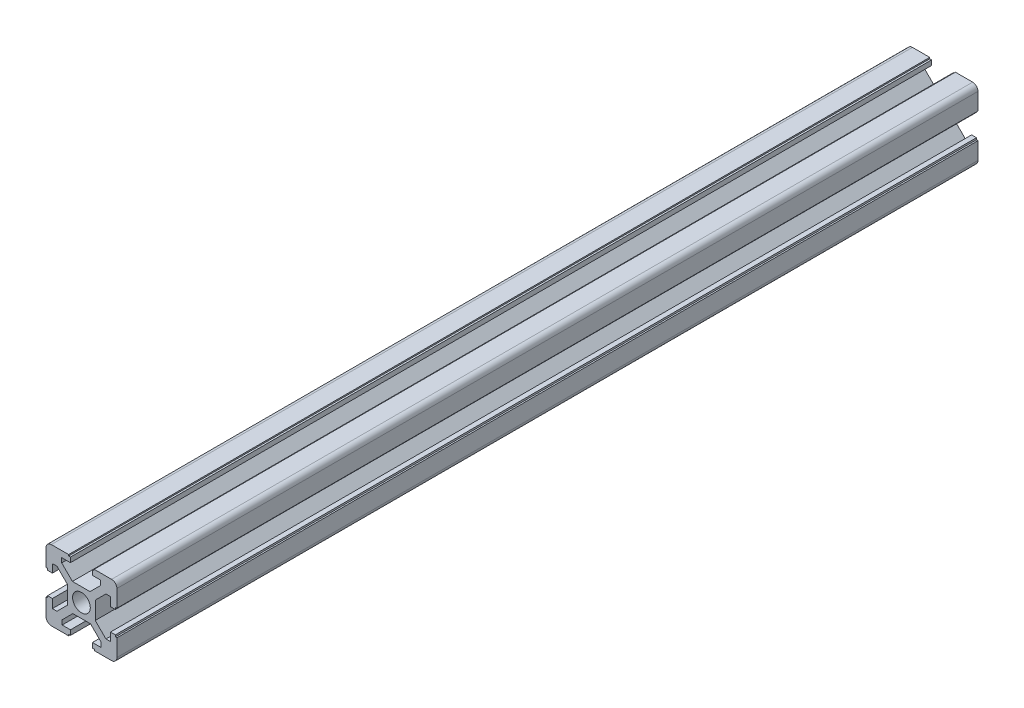
from build123d import *

# Parameters (mm, degrees)
SKETCH1_R           = 2.5
BOSS_EXTRUDE1_DEPTH = 243


with BuildPart() as part:
    # Sketch1 → Boss-Extrude1 (new body)
    with BuildSketch(Plane.XY):
        with BuildLine():
            Line((14.316619525, 10.387216168), (13.029112559, 10.387216168))
            Line((13.029112559, 10.387216168), (13.029112559, 12.855371932))
            Line((13.029112559, 12.855371932), (11.656738465, 12.855371932))
            Line((11.656738465, 12.855371932), (11.656738465, 12.336659272))
            Line((11.656738465, 12.336659272), (11.229112559, 12.336659272))
            Line((11.229112559, 12.336659272), (11.229112559, 7.521203168))
            ThreePointArc((11.229112559, 7.521203168), (11.668452387, 6.460542996), (12.729112559, 6.021203168))
            Line((12.729112559, 6.021203168), (17.624436699, 6.021203168))
            Line((17.624436699, 6.021203168), (17.624436699, 6.382997838))
            Line((17.624436699, 6.382997838), (18.129112559, 6.382997838))
            Line((18.129112559, 6.382997838), (18.129112559, 7.755371932))
            Line((18.129112559, 7.755371932), (15.794230869, 7.755371932))
            Line((15.794230869, 7.755371932), (15.794230869, 9.042878898))
            Line((15.794230869, 9.042878898), (18.806723903, 12.055371932))
            Line((18.806723903, 12.055371932), (23.784775289, 12.055371932))
            Line((23.784775289, 12.055371932), (26.797268323, 9.042878898))
            Line((26.797268323, 9.042878898), (26.797268323, 7.755371932))
            Line((26.797268323, 7.755371932), (24.329112559, 7.755371932))
            Line((24.329112559, 7.755371932), (24.329112559, 6.382997838))
            Line((24.329112559, 6.382997838), (24.847825219, 6.382997838))
            Line((24.847825219, 6.382997838), (24.847825219, 6.021203168))
            Line((24.847825219, 6.021203168), (29.729112559, 6.021203168))
            ThreePointArc((29.729112559, 6.021203168), (30.789772731, 6.460542996), (31.229112559, 7.521203168))
            Line((31.229112559, 7.521203168), (31.229112559, 12.350696072))
            Line((31.229112559, 12.350696072), (30.801486653, 12.350696072))
            Line((30.801486653, 12.350696072), (30.801486653, 12.855371932))
            Line((30.801486653, 12.855371932), (29.429112559, 12.855371932))
            Line((29.429112559, 12.855371932), (29.429112559, 10.520490242))
            Line((29.429112559, 10.520490242), (28.141605593, 10.520490242))
            Line((28.141605593, 10.520490242), (25.129112559, 13.532983276))
            Line((25.129112559, 13.532983276), (25.129112559, 18.511034662))
            Line((25.129112559, 18.511034662), (28.141605593, 21.523527696))
            Line((28.141605593, 21.523527696), (29.429112559, 21.523527696))
            Line((29.429112559, 21.523527696), (29.429112559, 19.055371932))
            Line((29.429112559, 19.055371932), (30.801486653, 19.055371932))
            Line((30.801486653, 19.055371932), (30.801486653, 19.574084592))
            Line((30.801486653, 19.574084592), (31.229112559, 19.574084592))
            Line((31.229112559, 19.574084592), (31.229112559, 24.389540696))
            ThreePointArc((31.229112559, 24.389540696), (30.789772731, 25.450200868), (29.729112559, 25.889540696))
            Line((29.729112559, 25.889540696), (24.833788419, 25.889540696))
            Line((24.833788419, 25.889540696), (24.833788419, 25.527746026))
            Line((24.833788419, 25.527746026), (24.329112559, 25.527746026))
            Line((24.329112559, 25.527746026), (24.329112559, 24.155371932))
            Line((24.329112559, 24.155371932), (26.663994249, 24.155371932))
            Line((26.663994249, 24.155371932), (26.663994249, 22.867864966))
            Line((26.663994249, 22.867864966), (23.651501215, 19.855371932))
            Line((23.651501215, 19.855371932), (18.673449829, 19.855371932))
            Line((18.673449829, 19.855371932), (15.660956795, 22.867864966))
            Line((15.660956795, 22.867864966), (15.660956795, 24.155371932))
            Line((15.660956795, 24.155371932), (18.129112559, 24.155371932))
            Line((18.129112559, 24.155371932), (18.129112559, 25.527746026))
            Line((18.129112559, 25.527746026), (17.610399899, 25.527746026))
            Line((17.610399899, 25.527746026), (17.610399899, 25.889540696))
            Line((17.610399899, 25.889540696), (12.729112559, 25.889540696))
            ThreePointArc((12.729112559, 25.889540696), (11.668452387, 25.450200868), (11.229112559, 24.389540696))
            Line((11.229112559, 24.389540696), (11.229112559, 19.560047792))
            Line((11.229112559, 19.560047792), (11.656738465, 19.560047792))
            Line((11.656738465, 19.560047792), (11.656738465, 19.055371932))
            Line((11.656738465, 19.055371932), (13.029112559, 19.055371932))
            Line((13.029112559, 19.055371932), (13.029112559, 21.390253622))
            Line((13.029112559, 21.390253622), (14.316619525, 21.390253622))
            Line((14.316619525, 21.390253622), (17.329112559, 18.377760588))
            Line((17.329112559, 18.377760588), (17.329112559, 13.399709202))
            Line((17.329112559, 13.399709202), (14.316619525, 10.387216168))
        make_face()
        with Locations((21.229112559, 15.955371932)):
            Circle(SKETCH1_R, mode=Mode.SUBTRACT)
    extrude(amount=BOSS_EXTRUDE1_DEPTH)


solid = part.part
